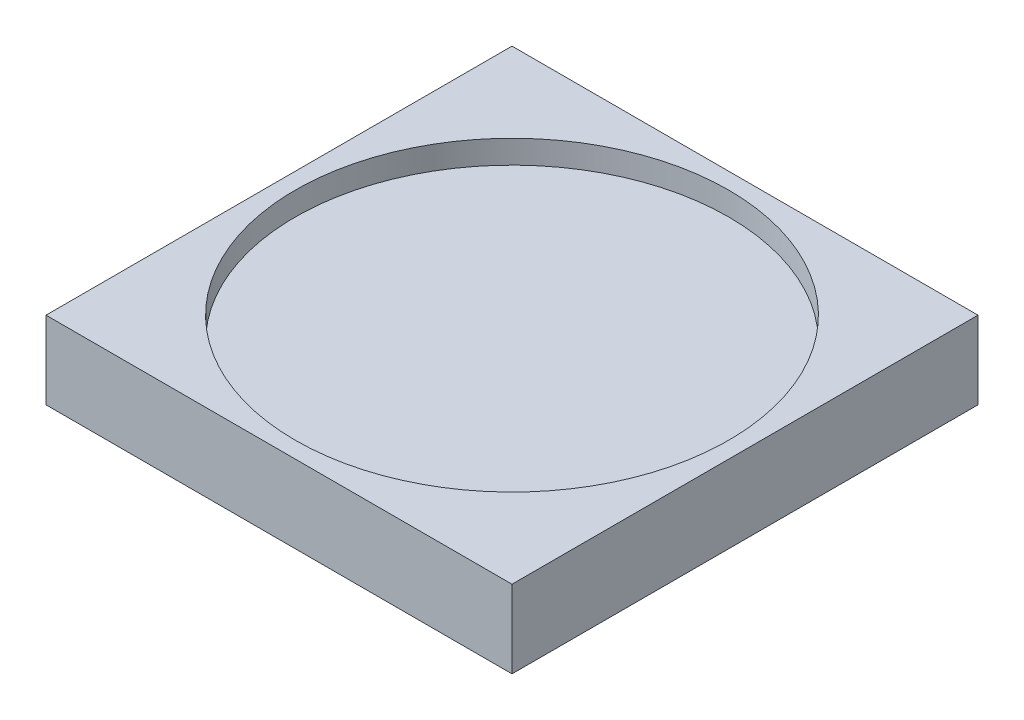
from build123d import *

# Parameters (mm, degrees)
SKETCH1_W           = 30
SKETCH1_H           = 30
BOSS_EXTRUDE1_DEPTH = 5
SKETCH2_R           = 13.95
CUT_EXTRUDE1_DEPTH  = 1.5


with BuildPart() as part:
    # Sketch1 → Boss-Extrude1 (new body)
    with BuildSketch(Plane(origin=(0, 0, 0), x_dir=(1, 0, 0), z_dir=(0, 1, 0))):
        Rectangle(SKETCH1_W, SKETCH1_H)
    extrude(amount=BOSS_EXTRUDE1_DEPTH)

    # Sketch2 → Cut-Extrude1 (cut)
    with BuildSketch(Plane(origin=(0, 5, 0), x_dir=(1, 0, 0), z_dir=(0, 1, 0))):
        Circle(SKETCH2_R)
    extrude(amount=-CUT_EXTRUDE1_DEPTH, mode=Mode.SUBTRACT)


solid = part.part
